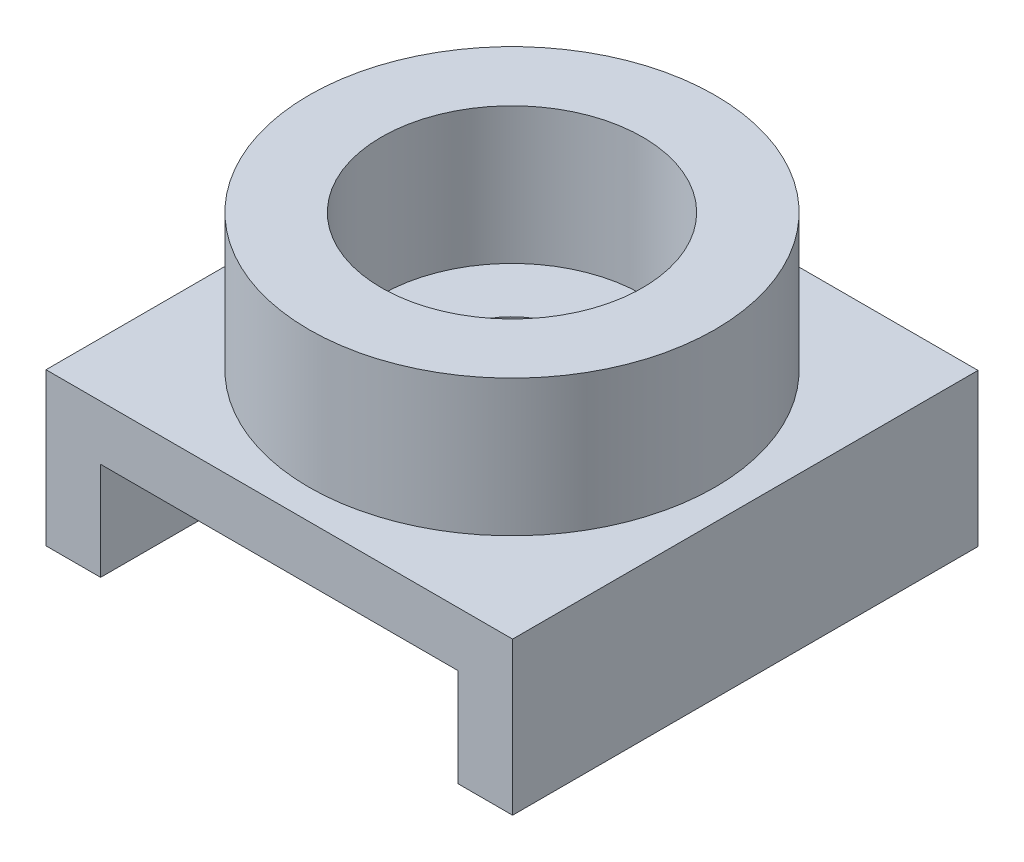
from build123d import *

# Parameters (mm, degrees)
BOSS_EXTRUDE1_DEPTH = 4.9784
SKETCH3_R           = 4.3434
SKETCH3_R_2         = 2.794
BOSS_EXTRUDE2_DEPTH = 2.921
CUT_EXTRUDE1_REACH  = 5.264
SKETCH4_R           = 1.397


with BuildPart() as part:
    # Sketch2 → Boss-Extrude1 (new body, symmetric)
    with BuildSketch(Plane.XY):
        Polygon((-3.8227, 0), (-4.9911, 0), (-4.9911, 3.2639), (4.9911, 3.2639), (4.9911, 0), (3.8227, 0), (3.8227, 2.0955), (-3.8227, 2.0955), align=None)
    extrude(amount=BOSS_EXTRUDE1_DEPTH, both=True)

    # Sketch3 → Boss-Extrude2 (add)
    with BuildSketch(Plane(origin=(0, 3.2639, 0), x_dir=(1, 0, 0), z_dir=(0, 1, 0))):
        Circle(SKETCH3_R)
        Circle(SKETCH3_R_2, mode=Mode.SUBTRACT)
    extrude(amount=BOSS_EXTRUDE2_DEPTH)

    # Sketch4 → Cut-Extrude1 (cut, up to next)
    with BuildSketch(Plane(origin=(0, 3.2639, 0), x_dir=(1, 0, 0), z_dir=(0, 1, 0)), mode=Mode.PRIVATE) as cut_extrude1_sk1:
        Circle(SKETCH4_R)
    cut_extrude1_tool1 = extrude(cut_extrude1_sk1.sketch, amount=-CUT_EXTRUDE1_REACH, mode=Mode.PRIVATE) & part.part
    add(cut_extrude1_tool1.solids().sort_by_distance((0, 3.2639, 0))[0], mode=Mode.SUBTRACT)


solid = part.part
